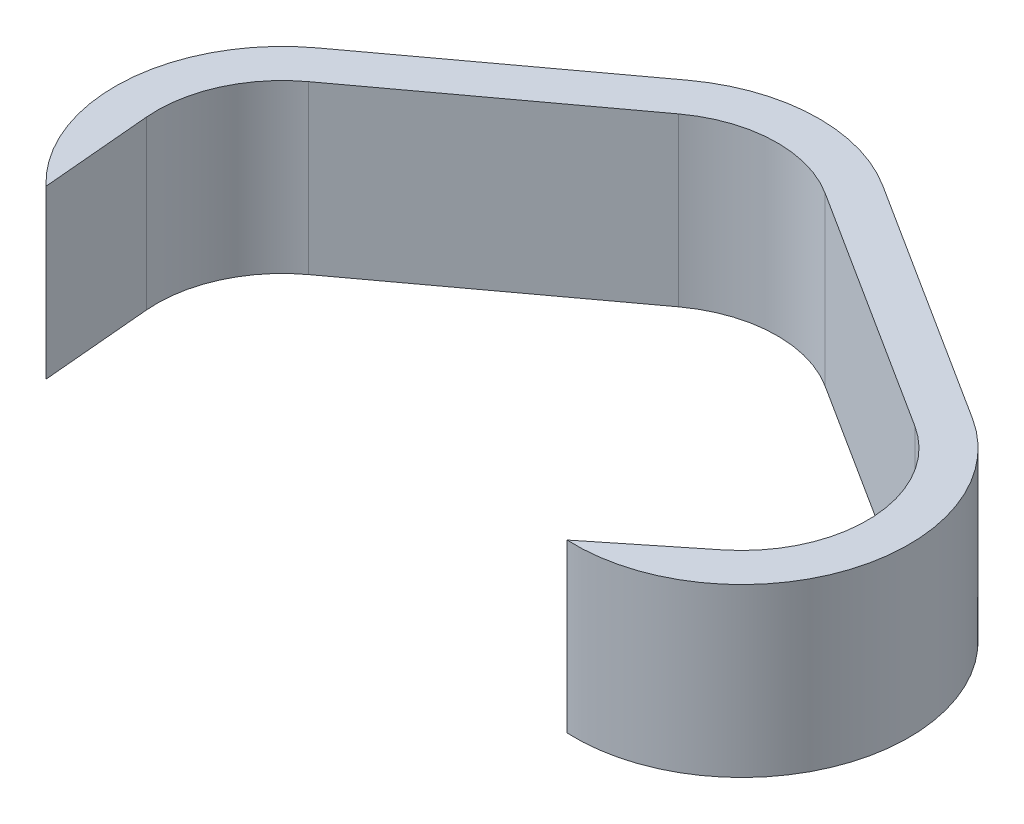
from build123d import *

# Parameters (mm, degrees)
BOSS_EXTRUDE1_DEPTH = 25.4


with BuildPart() as part:
    # Sketch1 → Boss-Extrude1 (new body)
    with BuildSketch(Plane(origin=(0, 0, 0), x_dir=(1, 0, 0), z_dir=(0, 1, 0))):
        with BuildLine():
            ThreePointArc((-11.307534998, 15.331084511), (-0.657073574, 19.03866472), (10.223658013, 16.074181685))
            Line((10.223658013, 16.074181685), (47.730081944, -7.781020346))
            ThreePointArc((47.730081944, -7.781020346), (56.527791269, -22.811130875), (49.427965792, -38.713847313))
            Line((49.427965792, -38.713847313), (36.32387238, -49.227658983))
            ThreePointArc((36.32387238, -49.227658983), (61.722416996, -31.519775069), (51.137967948, -2.422959784))
            Line((51.137967948, -2.422959784), (13.631544017, 21.432242246))
            ThreePointArc((13.631544017, 21.432242246), (-0.876098099, 25.384886293), (-15.07671333, 20.441446014))
            Line((-15.07671333, 20.441446014), (-47.420289399, -3.413756016))
            ThreePointArc((-47.420289399, -3.413756016), (-57.694182826, -22.271934185), (-49.846542995, -42.261889641))
            Line((-49.846542995, -42.261889641), (-51.320154567, -25.526120494))
            ThreePointArc((-51.320154567, -25.526120494), (-49.708739726, -16.022348708), (-43.651111067, -8.52411752))
            Line((-43.651111067, -8.52411752), (-11.307534998, 15.331084511))
        make_face()
    extrude(amount=BOSS_EXTRUDE1_DEPTH)


solid = part.part
